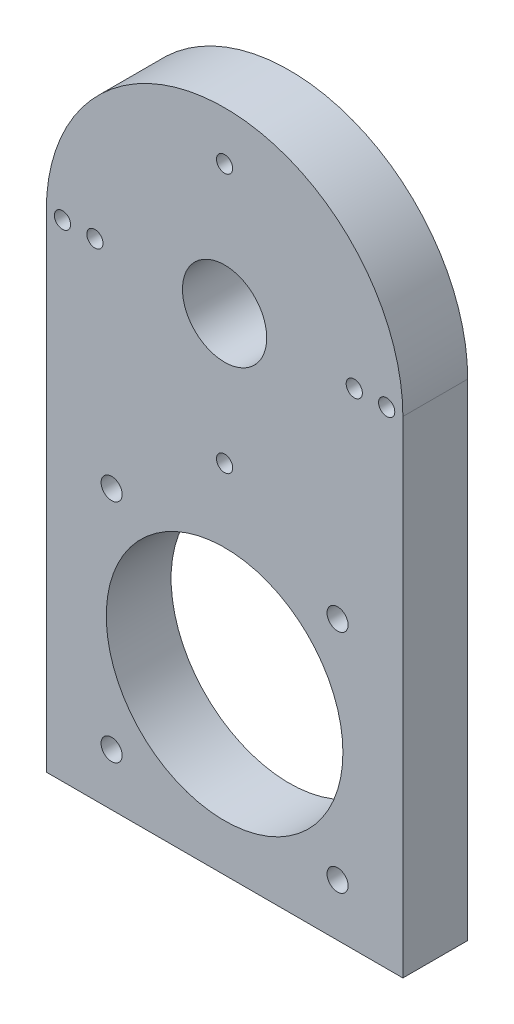
from build123d import *

# Parameters (mm, degrees)
SKETCH1_R                  = 13
BOSS_EXTRUDE1_DEPTH        = 20
F_5_0MM_DOWEL_HOLE1_D      = 5
F_5_0MM_DOWEL_HOLE2_REACH  = 228.164
F_5_0MM_DOWEL_HOLE2_BORE_R = 2.5
F_5_0MM_DOWEL_HOLE3_D      = 5
SKETCH9_R                  = 36.5
CUT_EXTRUDE1_DEPTH         = 214.781968135
F_6_0MM_DOWEL_HOLE1_D      = 6.5


with BuildPart() as part:
    # Sketch1 → Boss-Extrude1 (new body)
    with BuildSketch(Plane.XY):
        with BuildLine():
            Line((-57.251461988, 0), (52.748538012, 0))
            Line((52.748538012, 0), (52.748538012, 150))
            ThreePointArc((52.748538012, 150), (-2.251461988, 205), (-57.251461988, 150))
            Line((-57.251461988, 150), (-57.251461988, 0))
        make_face()
        with Locations((-2.251461988, 150)):
            Circle(SKETCH1_R, mode=Mode.SUBTRACT)
    extrude(amount=BOSS_EXTRUDE1_DEPTH)

    # Ø5.0mm Dowel Hole1 (through all)
    with Locations(Plane(origin=(-2.251461988, 190, 20), x_dir=(1, 0, 0), z_dir=(0, 0, 1))):
        with Locations((0, 0), (40, -40), (0, -80), (-40, -40)):
            Hole(F_5_0MM_DOWEL_HOLE1_D / 2)

    # Ø5.0mm Dowel Hole2 bore (on position points) → Ø5.0mm Dowel Hole2 (cut, up to next)
    with BuildSketch(Plane(origin=(-42.251461988, 0, 10), x_dir=(0, 0, -1), z_dir=(0, -1, 0)), mode=Mode.PRIVATE) as f_5_0mm_dowel_hole2_sk1:
        Circle(F_5_0MM_DOWEL_HOLE2_BORE_R)
    f_5_0mm_dowel_hole2_tool1 = extrude(f_5_0mm_dowel_hole2_sk1.sketch, amount=-F_5_0MM_DOWEL_HOLE2_REACH, mode=Mode.PRIVATE) & part.part
    # Ø5.0mm Dowel Hole2 bore (on position points) → Ø5.0mm Dowel Hole2 (cut, up to next)
    with BuildSketch(Plane(origin=(-42.251461988, 0, 10), x_dir=(0, 0, -1), z_dir=(0, -1, 0)), mode=Mode.PRIVATE) as f_5_0mm_dowel_hole2_sk2:
        with Locations((0, 80)):
            Circle(F_5_0MM_DOWEL_HOLE2_BORE_R)
    f_5_0mm_dowel_hole2_tool2 = extrude(f_5_0mm_dowel_hole2_sk2.sketch, amount=-F_5_0MM_DOWEL_HOLE2_REACH, mode=Mode.PRIVATE) & part.part
    add(f_5_0mm_dowel_hole2_tool1.solids().sort_by_distance((-42.251462, 0, 10))[0], mode=Mode.SUBTRACT)
    add(f_5_0mm_dowel_hole2_tool2.solids().sort_by_distance((37.748538, 0, 10))[0], mode=Mode.SUBTRACT)

    # Ø5.0mm Dowel Hole3 (through all)
    with Locations(Plane(origin=(-52.251461988, 150, 20), x_dir=(1, 0, 0), z_dir=(0, 0, 1))):
        with Locations((0, 0), (100, 0)):
            Hole(F_5_0MM_DOWEL_HOLE3_D / 2)

    # Sketch9 → Cut-Extrude1 (cut, through all)
    with BuildSketch(Plane.XY.offset(20)):
        with Locations((-2.251461988, 51)):
            Circle(SKETCH9_R)
    extrude(amount=-CUT_EXTRUDE1_DEPTH, mode=Mode.SUBTRACT)

    # Ø6.0mm Dowel Hole1 (through all)
    with Locations(Plane(origin=(-37.101461988, 85.85, 20), x_dir=(1, 0, 0), z_dir=(0, 0, 1))):
        with Locations((0, 0), (69.7, 0), (69.7, -69.7), (0, -69.7)):
            Hole(F_6_0MM_DOWEL_HOLE1_D / 2)


solid = part.part
